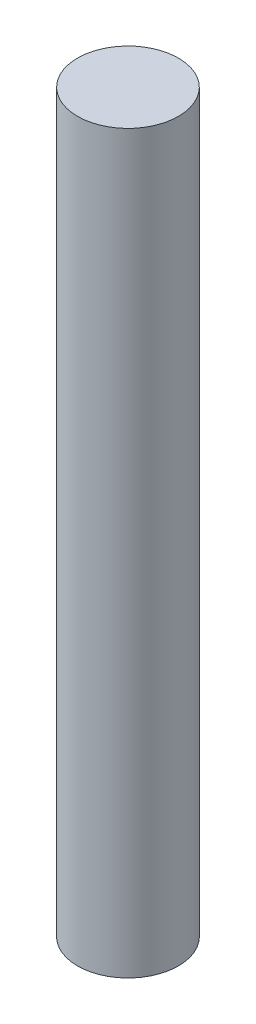
from build123d import *

# Parameters (mm, degrees)
SKETCH1_R           = 5
BOSS_EXTRUDE1_DEPTH = 72.9


with BuildPart() as part:
    # Sketch1 → Boss-Extrude1 (new body)
    with BuildSketch(Plane(origin=(0, 0, 0), x_dir=(1, 0, 0), z_dir=(0, 1, 0))):
        with Locations((-5.119320136, 3.65665724)):
            Circle(SKETCH1_R)
    extrude(amount=BOSS_EXTRUDE1_DEPTH)


solid = part.part
